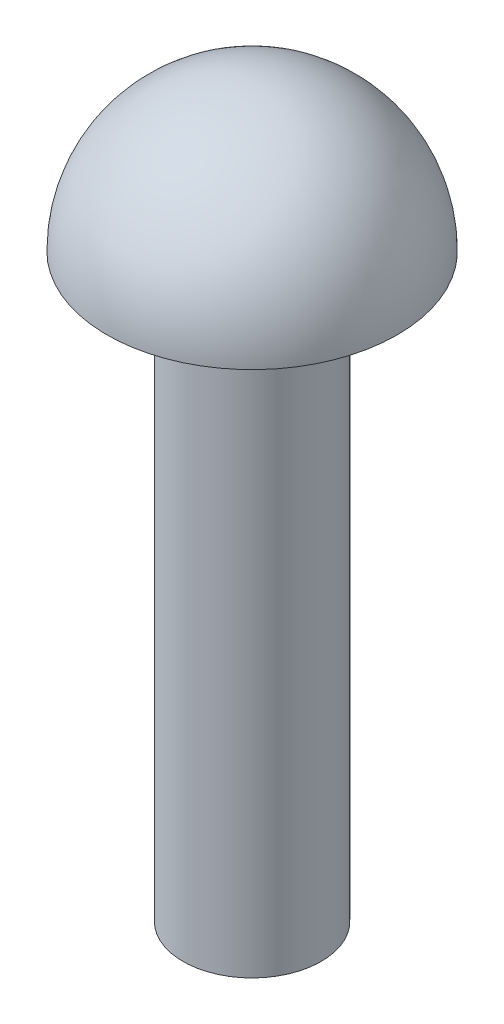
from build123d import *


with BuildPart() as part:
    # Croquis1 → Revolución1 (revolve)
    with BuildSketch(Plane.XY):
        with BuildLine():
            Line((0, 0), (4.7625, 0))
            Line((4.7625, 0), (4.7625, 40))
            Line((4.7625, 40), (10, 40))
            ThreePointArc((10, 40), (7.071067812, 47.071067812), (0, 50))
            Line((0, 50), (0, 0))
        make_face()
    revolve(axis=Axis((0, 0, 0), (0, 1, 0)))


solid = part.part
